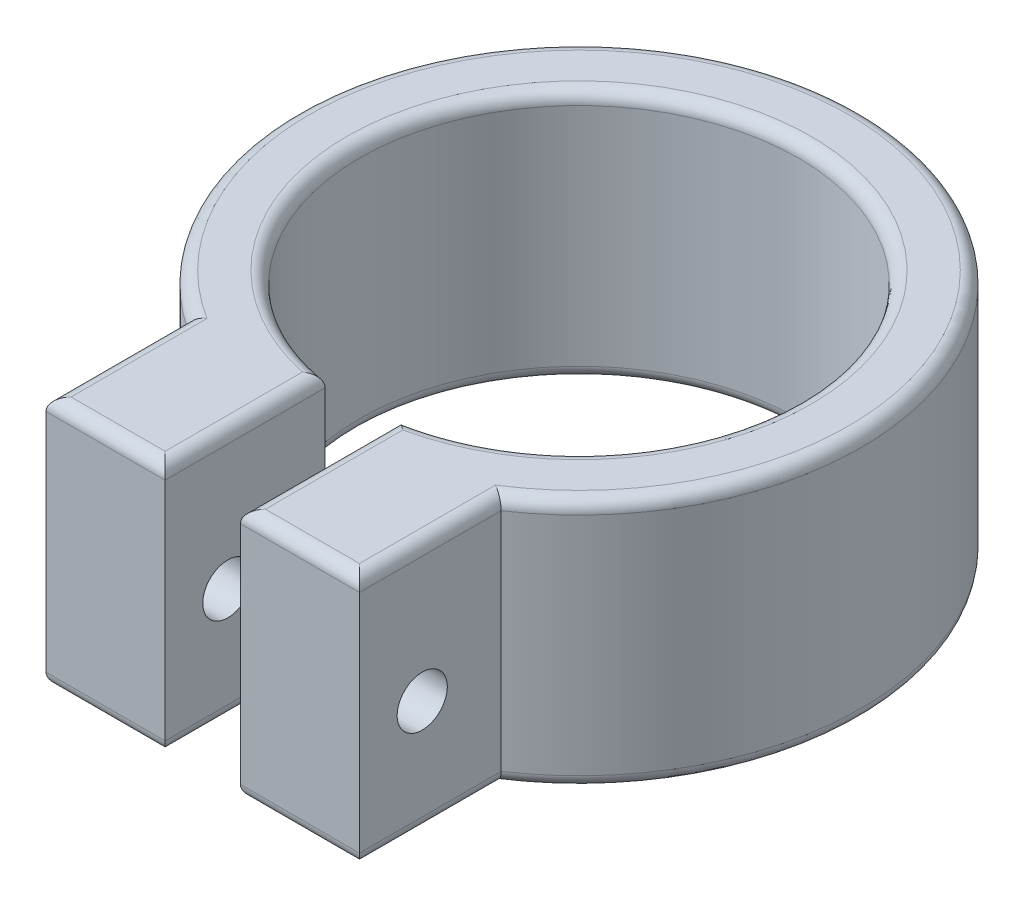
from build123d import *

# Parameters (mm, degrees)
SKETCH1_R           = 17.5
BOSS_EXTRUDE1_DEPTH = 20
SKETCH2_W           = 6
SKETCH2_H           = 12.75906035
CUT_EXTRUDE2_DEPTH  = 20
CUT_EXTRUDE5_DEPTH  = 20
FILLET5_R           = 1
SKETCH6_R           = 2
CUT_EXTRUDE7_DEPTH  = 29


with BuildPart() as part:
    # Sketch1 → Boss-Extrude1 (new body)
    with BuildSketch(Plane(origin=(0, 0, 0), x_dir=(1, 0, 0), z_dir=(0, 1, 0))):
        with BuildLine():
            Line((0, 30), (0, 0))
            Line((0, 0), (45, 0))
            Line((45, 0), (45, 30))
            ThreePointArc((45, 30), (22.5, 52.5), (0, 30))
        make_face()
        with Locations((22.5, 30)):
            Circle(SKETCH1_R, mode=Mode.SUBTRACT)
    extrude(amount=BOSS_EXTRUDE1_DEPTH)

    # Sketch2 → Cut-Extrude2 (cut)
    with BuildSketch(Plane(origin=(0, 20, 0), x_dir=(1, 0, 0), z_dir=(0, 1, 0))):
        with Locations((22.5, 6.379530175)):
            Rectangle(SKETCH2_W, SKETCH2_H)
    extrude(amount=-CUT_EXTRUDE2_DEPTH, mode=Mode.SUBTRACT)

    # Sketch5 → Cut-Extrude5 (cut)
    with BuildSketch(Plane(origin=(0, 20, 0), x_dir=(1, 0, 0), z_dir=(0, 1, 0))):
        with BuildLine():
            Line((10, 0), (10, 11.291713066))
            ThreePointArc((10, 11.291713066), (2.656865167, 19.393398282), (0, 30))
            Line((0, 30), (0, 0))
            Line((0, 0), (10, 0))
        make_face()
        with BuildLine():
            Line((45, 0), (45, 30))
            ThreePointArc((45, 30), (42.343134833, 19.393398282), (35, 11.291713066))
            Line((35, 11.291713066), (35, 0))
            Line((35, 0), (45, 0))
        make_face()
    extrude(amount=-CUT_EXTRUDE5_DEPTH, mode=Mode.SUBTRACT)

    # Fillet5
    fillet5_edges = [part.edges().sort_by_distance(p)[0] for p in [
        (22.5, 0, -47.5),
        (22.5, 20, -47.5),
        (30.25, 0, 0),
        (30.25, 20, 0),
        (19.5, 0, -6.379530175),
        (25.5, 0, -6.379530175),
        (25.5, 20, -6.379530175),
        (19.5, 20, -6.379530175),
        (14.75, 0, 0),
        (14.75, 20, 0),
        (10, 0, -5.645856533),
        (10, 20, -5.645856533),
        (22.5, 20, -52.5),
        (35, 20, -5.645856533),
        (35, 0, -5.645856533),
        (22.5, 0, -52.5),
    ]]
    fillet(fillet5_edges, radius=FILLET5_R)

    # Sketch6 → Cut-Extrude7 (cut)
    with BuildSketch(Plane(origin=(35, 0, 0), x_dir=(0, 0, -1), z_dir=(1, 0, 0))):
        with Locations((5, 9)):
            Circle(SKETCH6_R)
    extrude(amount=-CUT_EXTRUDE7_DEPTH, mode=Mode.SUBTRACT)


solid = part.part
